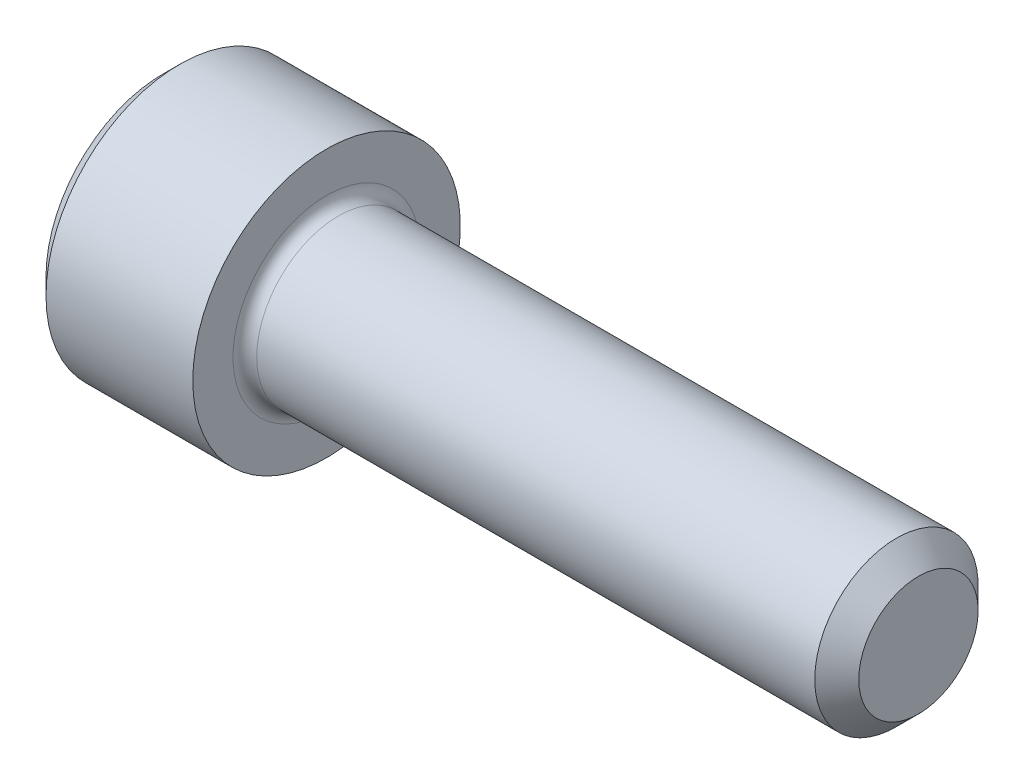
from build123d import *

# Parameters (mm, degrees)
FILLET1_R   = 0.254
HEX_2_DEPTH = 1.6256


with BuildPart() as part:
    # BodySke → Base-Revolve (revolve)
    with BuildSketch(Plane.XY):
        Polygon((0, 0), (0, 2.5146), (0.3556, 2.8702), (3.5052, 2.8702), (3.5052, 1.7526), (15.73276, 1.7526), (16.2052, 1.28016), (16.2052, 0), align=None)
    revolve(axis=Axis((-31.75, 0, 0), (1, 0, 0)))

    # Fillet1
    fillet1_edges = [part.edges().sort_by_distance(p)[0] for p in [
        (3.5052, -1.7526, 0),
    ]]
    fillet(fillet1_edges, radius=FILLET1_R)

    # Sketch2 → Hex-PreBroach (revolve, cut)
    with BuildSketch(Plane.XY):
        Polygon((0, 1.3843), (1.6256, 1.3843), (2.424825978, 0), (0, 0), align=None)
    revolve(axis=Axis((0, 0, 0), (1, 0, 0)), mode=Mode.SUBTRACT)

    # Sketch3 → Hex 2 (cut)
    with BuildSketch(Plane(origin=(0, 0, 0), x_dir=(0, 0.5, 0.866025404), z_dir=(-1, 0, 0))):
        Polygon((0.799225978, 1.3843), (-0.799225978, 1.3843), (-1.598451955, 0), (-0.799225978, -1.3843), (0.799225978, -1.3843), (1.598451955, 0), align=None)
    extrude(amount=-HEX_2_DEPTH, mode=Mode.SUBTRACT)


solid = part.part
